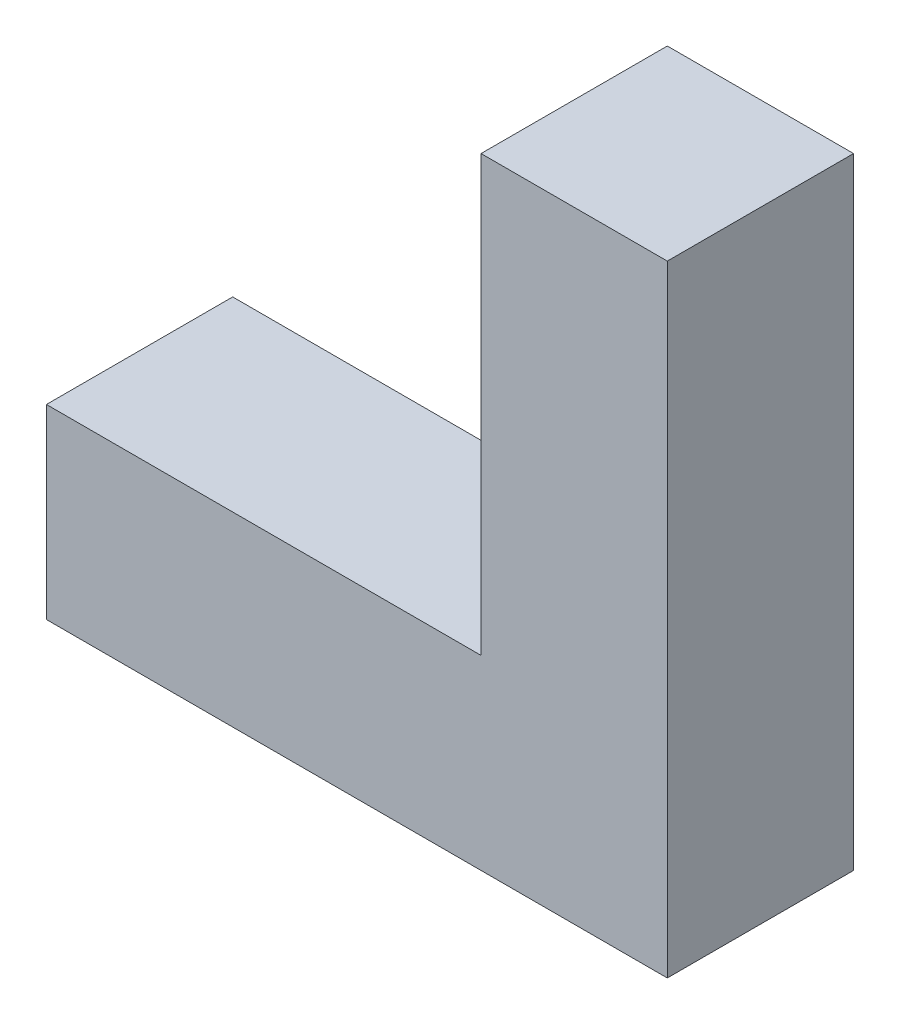
from build123d import *

# Parameters (mm, degrees)
BOSS_EXTRUDE1_DEPTH = 60


with BuildPart() as part:
    # Sketch2 → Boss-Extrude1 (new body)
    with BuildSketch(Plane.XY):
        Polygon((0, 0), (-140, 0), (-140, -60), (60, -60), (60, 140), (0, 140), align=None)
    extrude(amount=BOSS_EXTRUDE1_DEPTH)


solid = part.part
